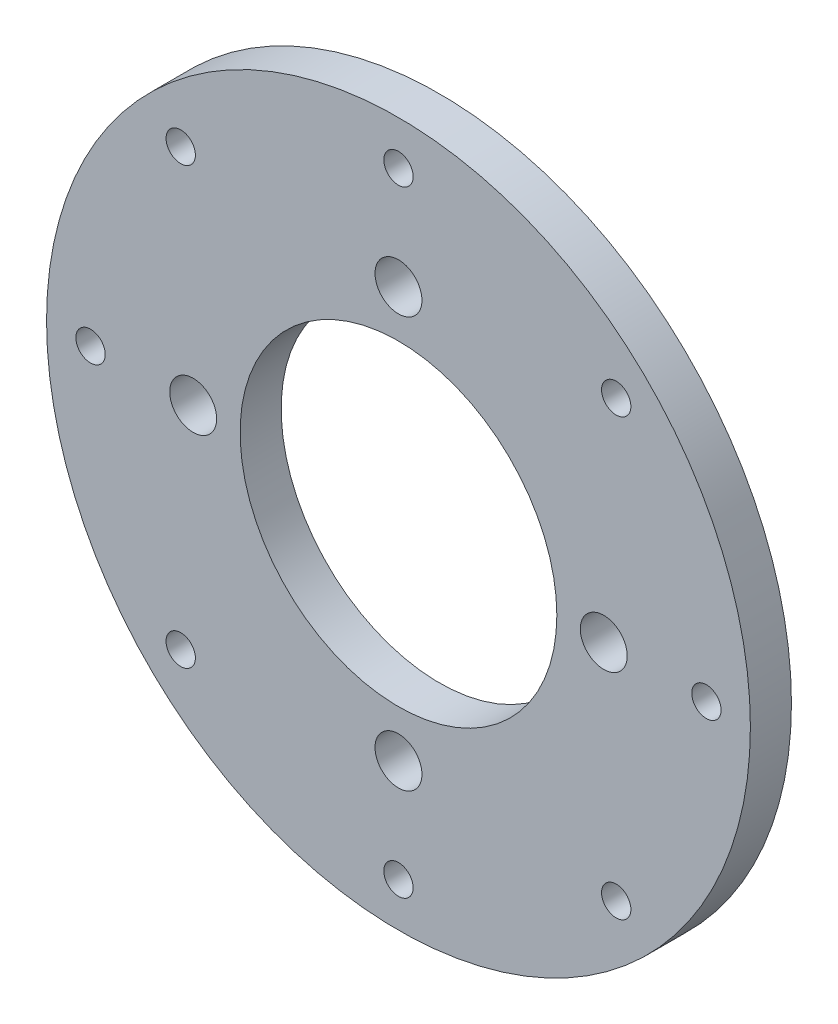
from build123d import *

# Parameters (mm, degrees)
CROQUIS1_R              = 60
SALIENTE_EXTRUIR1_DEPTH = 7
CROQUIS2_R              = 27
CORTAR_EXTRUIR1_DEPTH   = 8
CROQUIS3_R              = 4
CORTAR_EXTRUIR2_DEPTH   = 8
CROQUIS5_R              = 2.5
CORTAR_EXTRUIR3_DEPTH   = 8


with BuildPart() as part:
    # Croquis1 → Saliente-Extruir1 (new body)
    with BuildSketch(Plane.XY):
        Circle(CROQUIS1_R)
    extrude(amount=SALIENTE_EXTRUIR1_DEPTH)

    # Croquis2 → Cortar-Extruir1 (cut, through all)
    with BuildSketch(Plane.XY.offset(7)):
        Circle(CROQUIS2_R)
    extrude(amount=-CORTAR_EXTRUIR1_DEPTH, mode=Mode.SUBTRACT)

    # Croquis3 → Cortar-Extruir2 (cut, through all)
    with BuildSketch(Plane.XY.offset(7)):
        with Locations((0, 35)):
            Circle(CROQUIS3_R)
        with Locations((35, 0)):
            Circle(CROQUIS3_R)
        with Locations((0, -35)):
            Circle(CROQUIS3_R)
        with Locations((-35, 0)):
            Circle(CROQUIS3_R)
    extrude(amount=-CORTAR_EXTRUIR2_DEPTH, mode=Mode.SUBTRACT)

    # Croquis5 → Cortar-Extruir3 (cut, through all)
    with BuildSketch(Plane.XY.offset(7)):
        with Locations((37.123106012, 37.123106012)):
            Circle(CROQUIS5_R)
        with Locations((52.5, 0)):
            Circle(CROQUIS5_R)
        with Locations((37.123106012, -37.123106012)):
            Circle(CROQUIS5_R)
        with Locations((-52.5, 0)):
            Circle(CROQUIS5_R)
        with Locations((-37.123106012, 37.123106012)):
            Circle(CROQUIS5_R)
        with Locations((0, 52.5)):
            Circle(CROQUIS5_R)
        with Locations((0, -52.5)):
            Circle(CROQUIS5_R)
        with Locations((-37.123106012, -37.123106012)):
            Circle(CROQUIS5_R)
    extrude(amount=-CORTAR_EXTRUIR3_DEPTH, mode=Mode.SUBTRACT)


solid = part.part
